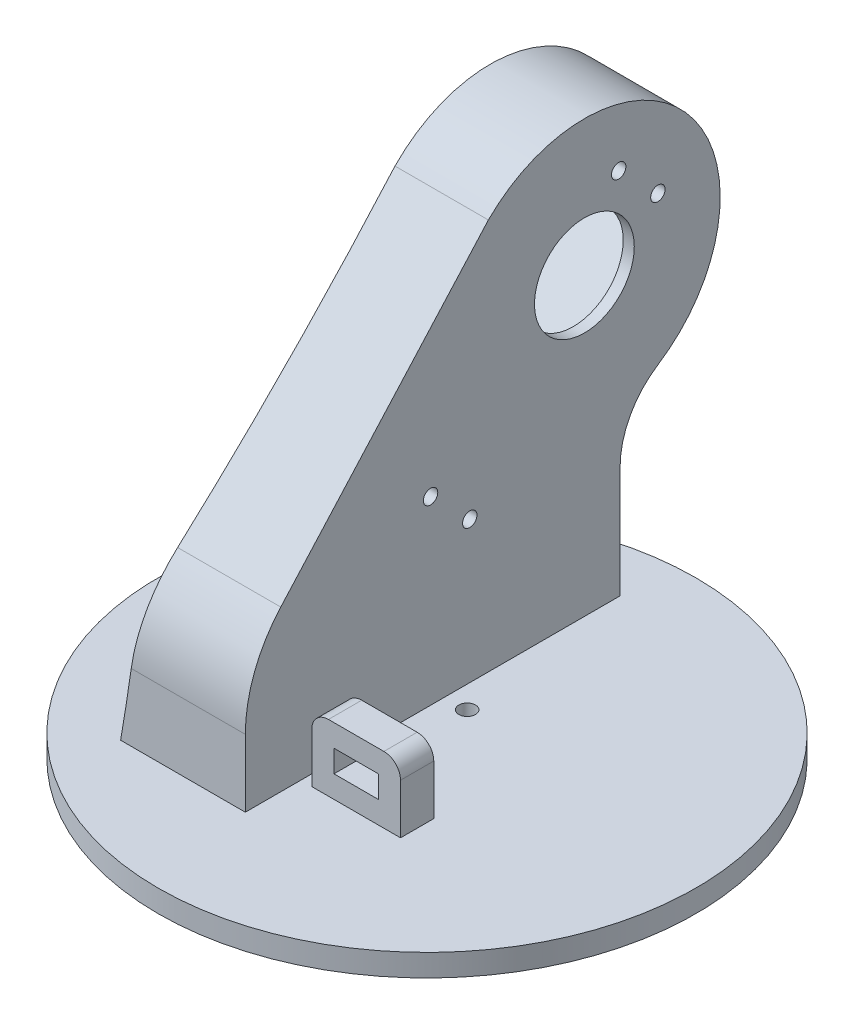
from build123d import *

# Parameters (mm, degrees)
SKETCH2_R                = 48.5
BOSS_EXTRUDE1_DEPTH      = 4
SKETCH4_R                = 1.5
CUT_EXTRUDE2_DEPTH       = 5
SKETCH5_R                = 3.75
CUT_EXTRUDE3_DEPTH       = 1.5
BOSS_EXTRUDE2_DEPTH      = 14
CUT_EXTRUDE5_REACH       = 44.5
SKETCH9_R                = 1.3
CUT_EXTRUDE6_DEPTH       = 67.5
CUT_EXTRUDE9_REACH       = 46.5
SKETCH11_R               = 9
BOSS_EXTRUDE7_DEPTH      = 9
BOSS_EXTRUDE7_DEPTH_BACK = 14
BOSS_EXTRUDE10_DEPTH     = 9
SKETCH27_W               = 16
SKETCH27_H               = 6
BOSS_EXTRUDE11_DEPTH     = 12
FILLET6_R                = 3
CUT_EXTRUDE16_REACH      = 77.672
SKETCH28_W               = 8
SKETCH28_H               = 4
CUT_EXTRUDE17_DEPTH      = 49.5
CUT_EXTRUDE17_DEPTH_BACK = 57.89561214


with BuildPart() as part:
    # Sketch2 → Boss-Extrude1 (new body)
    with BuildSketch(Plane(origin=(0, 0, 0), x_dir=(1, 0, 0), z_dir=(0, 1, 0))):
        Circle(SKETCH2_R)
    extrude(amount=BOSS_EXTRUDE1_DEPTH)

    # Sketch4 → Cut-Extrude2 (cut, through all)
    with BuildSketch(Plane.XZ):
        with Locations((0, 7.25)):
            Circle(SKETCH4_R)
        with Locations((0, -7.25)):
            Circle(SKETCH4_R)
    extrude(amount=-CUT_EXTRUDE2_DEPTH, mode=Mode.SUBTRACT)

    # Sketch5 → Cut-Extrude3 (cut)
    with BuildSketch(Plane.XZ):
        Circle(SKETCH5_R)
    extrude(amount=-CUT_EXTRUDE3_DEPTH, mode=Mode.SUBTRACT)

    # Sketch7 → Boss-Extrude2 (add)
    with BuildSketch(Plane(origin=(-4, 0, 0), x_dir=(0, 0, -1), z_dir=(1, 0, 0))):
        with BuildLine():
            Line((35.838240239, 4), (35.838240239, 24.116109522))
            ThreePointArc((35.838240239, 24.116109522), (38.028688753, 32.721810064), (44.066915997, 39.233027943))
            ThreePointArc((44.066915997, 39.233027943), (49.118651286, 70.801932352), (17.192816244, 72.492142963))
            Line((17.192816244, 72.492142963), (-21.454056035, 33.845270684))
            ThreePointArc((-21.454056035, 33.845270684), (-26.873374818, 25.734686963), (-28.776386505, 16.167601154))
            Line((-28.776386505, 16.167601154), (-28.776386505, 4))
            Line((-28.776386505, 4), (35.838240239, 4))
        make_face()
    extrude(amount=-BOSS_EXTRUDE2_DEPTH)

    # Sketch8 → Cut-Extrude5 (cut, up to next)
    with BuildSketch(Plane(origin=(-6, 0, 0), x_dir=(0, 0, -1), z_dir=(1, 0, 0)), mode=Mode.PRIVATE) as cut_extrude5_sk1:
        Polygon((3.227457316, 42.970434849), (32.218835345, 71.961812877), (47.06807775, 57.112570472), (18.076699721, 28.121192444), align=None)
    cut_extrude5_tool1 = extrude(cut_extrude5_sk1.sketch, amount=-CUT_EXTRUDE5_REACH, mode=Mode.PRIVATE) & part.part
    add(cut_extrude5_tool1.solids().sort_by_distance((-6, 50.041503, -25.147768))[0], mode=Mode.SUBTRACT)

    # Sketch9 → Cut-Extrude6 (cut, through all)
    with BuildSketch(Plane.ZY.offset(18)):
        with Locations((-38.582796375, 70.547599315)):
            Circle(SKETCH9_R)
        with Locations((-45.653864187, 63.476531503)):
            Circle(SKETCH9_R)
        with Locations((-11.71273869, 29.535406006)):
            Circle(SKETCH9_R)
        with Locations((-4.641670878, 36.606473818)):
            Circle(SKETCH9_R)
    extrude(amount=-CUT_EXTRUDE6_DEPTH, mode=Mode.SUBTRACT)

    # Sketch11 → Cut-Extrude9 (cut, up to next)
    with BuildSketch(Plane(origin=(-4, 0, 0), x_dir=(0, 0, -1), z_dir=(1, 0, 0)), mode=Mode.PRIVATE) as cut_extrude9_sk1:
        with Locations((32.39561204, 57.289347168)):
            Circle(SKETCH11_R)
    cut_extrude9_tool1 = extrude(cut_extrude9_sk1.sketch, amount=-CUT_EXTRUDE9_REACH, mode=Mode.PRIVATE) & part.part
    add(cut_extrude9_tool1.solids().sort_by_distance((-4, 57.289347, -32.395612))[0], mode=Mode.SUBTRACT)

    # Sketch17 → Boss-Extrude7 (add, two sides)
    with BuildSketch(Plane.ZY.offset(18)) as boss_extrude7_sk:
        with BuildLine():
            ThreePointArc((28.776386505, 16.167601154), (27.123973821, 25.105731079), (22.385173182, 32.862302662))
            ThreePointArc((22.385173182, 32.862302662), (21.926270321, 33.360091302), (21.454056035, 33.845270684))
            Line((21.454056035, 33.845270684), (-17.192816244, 72.492142963))
            Line((-17.192816244, 72.492142963), (20.153274432, 30.85765023))
            ThreePointArc((20.153274432, 30.85765023), (24.322572701, 24.032347355), (25.776386505, 16.167601154))
            Line((25.776386505, 16.167601154), (25.776386505, 4))
            Line((25.776386505, 4), (28.776386505, 4))
            Line((28.776386505, 4), (28.776386505, 16.167601154))
        make_face()
        with BuildLine():
            Line((22.385173182, 32.862302662), (-15.071495901, 74.613463307))
            ThreePointArc((-15.071495901, 74.613463307), (-51.452098623, 72.687409354), (-45.695470037, 36.713541539))
            ThreePointArc((-45.695470037, 36.713541539), (-40.663614001, 31.28752664), (-38.838240239, 24.116109522))
            Line((-38.838240239, 24.116109522), (-38.838240239, 4))
            Line((-38.838240239, 4), (-35.838240239, 4))
            Line((-35.838240239, 4), (-35.838240239, 24.116109522))
            ThreePointArc((-35.838240239, 24.116109522), (-38.028688753, 32.721810064), (-44.066915997, 39.233027943))
            ThreePointArc((-44.066915997, 39.233027943), (-49.118651286, 70.801932352), (-17.192816244, 72.492142963))
            Line((-17.192816244, 72.492142963), (21.454056035, 33.845270684))
            ThreePointArc((21.454056035, 33.845270684), (21.926270321, 33.360091302), (22.385173182, 32.862302662))
        make_face()
    extrude(amount=BOSS_EXTRUDE7_DEPTH)
    extrude(boss_extrude7_sk.sketch, amount=-BOSS_EXTRUDE7_DEPTH_BACK)

    # Sketch25 → Boss-Extrude10 (add)
    with BuildSketch(Plane.ZY.offset(18)):
        with BuildLine():
            ThreePointArc((-44.066915997, 39.233027943), (-38.028688753, 32.721810064), (-35.838240239, 24.116109522))
            Line((-35.838240239, 24.116109522), (-35.838240239, 4))
            Line((-35.838240239, 4), (-27.838240239, 4))
            add(Edge.make_bspline(
                [(-44.066915997, 39.233027943), (-36.217415427, 34.159241535), (-9.669096592, 17.105596636), (-27.838240239, 4)],
                knots=[0, 0, 0, 0, 1, 1, 1, 1], degree=3))
        make_face()
        with BuildLine():
            add(Edge.make_bspline(
                [(10.649740153, 41.452462744), (25.981861033, 24.35977476), (19.776386505, 4)],
                knots=[0, 0, 0, 1, 1, 1], degree=2))
            Line((19.776386505, 4), (25.776386505, 4))
            Line((25.776386505, 4), (25.776386505, 16.167601154))
            ThreePointArc((25.776386505, 16.167601154), (24.322572701, 24.032347355), (20.153274432, 30.85765023))
            Line((20.153274432, 30.85765023), (10.649740153, 41.452462744))
        make_face()
    extrude(amount=BOSS_EXTRUDE10_DEPTH)

    # Sketch27 → Boss-Extrude11 (add)
    with BuildSketch(Plane(origin=(0, 4, 0), x_dir=(1, 0, 0), z_dir=(0, 1, 0))):
        with Locations((6, -15.776386505)):
            Rectangle(SKETCH27_W, SKETCH27_H)
    extrude(amount=BOSS_EXTRUDE11_DEPTH)

    # Fillet6
    fillet6_edges = [part.edges().sort_by_distance(p)[0] for p in [
        (-2, 16, 15.776386505),
        (14, 16, 15.776386505),
    ]]
    fillet(fillet6_edges, radius=FILLET6_R)

    # Sketch28 → Cut-Extrude16 (cut, up to next)
    with BuildSketch(Plane.XY.offset(18.776386505), mode=Mode.PRIVATE) as cut_extrude16_sk1:
        with Locations((6, 10)):
            Rectangle(SKETCH28_W, SKETCH28_H)
    cut_extrude16_tool1 = extrude(cut_extrude16_sk1.sketch, amount=-CUT_EXTRUDE16_REACH, mode=Mode.PRIVATE) & part.part
    add(cut_extrude16_tool1.solids().sort_by_distance((6, 10, 18.776387))[0], mode=Mode.SUBTRACT)

    # Sketch29 → Cut-Extrude17 (cut, two sides)
    with BuildSketch(Plane.XY) as cut_extrude17_sk:
        with BuildLine():
            Line((-21, 81.789347168), (-27, 81.789347168))
            Line((-27, 81.789347168), (-27, 4))
            Line((-27, 4), (-26.5, 4))
            add(Edge.make_bspline(
                [(-21, 81.789347168), (-19.81566604, 42.545643995), (-26.5, 4)],
                knots=[0, 0, 0, 1, 1, 1], degree=2))
        make_face()
    extrude(amount=CUT_EXTRUDE17_DEPTH, mode=Mode.SUBTRACT)
    extrude(cut_extrude17_sk.sketch, amount=-CUT_EXTRUDE17_DEPTH_BACK, mode=Mode.SUBTRACT)


solid = part.part
